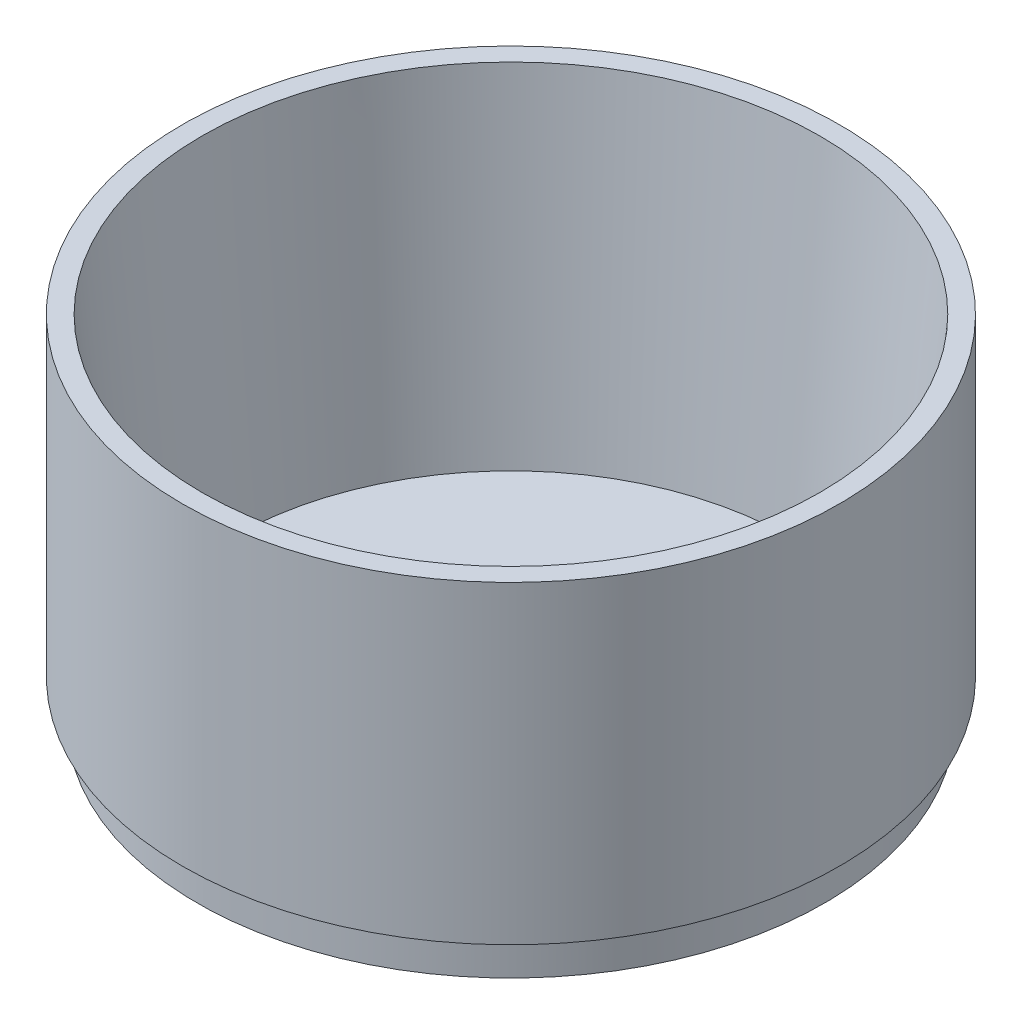
from build123d import *

# Parameters (mm, degrees)
SKETCH1_R           = 53.18125
BOSS_EXTRUDE1_DEPTH = 50.8
SKETCH2_R           = 50.8
SKETCH2_R_2         = 47.625
BOSS_EXTRUDE2_DEPTH = 6.35
SKETCH3_R           = 50.00625
CUT_EXTRUDE1_DEPTH  = 53.975
CUT_EXTRUDE1_DRAFT  = -5
SKETCH4_R           = 4.7625
CUT_EXTRUDE3_DEPTH  = 3.175


with BuildPart() as part:
    # Sketch1 → Boss-Extrude1 (new body)
    with BuildSketch(Plane(origin=(0, 0, 0), x_dir=(1, 0, 0), z_dir=(0, 1, 0))):
        with Locations(Location((0, 0, 0), (0, 0, 270))):
            Circle(SKETCH1_R)
    extrude(amount=BOSS_EXTRUDE1_DEPTH)

    # Sketch2 → Boss-Extrude2 (add)
    with BuildSketch(Plane.XZ):
        with Locations(Location((0, 0, 0), (0, 0, 270))):
            Circle(SKETCH2_R)
        Circle(SKETCH2_R_2, mode=Mode.SUBTRACT)
        Circle(SKETCH2_R_2)
    extrude(amount=BOSS_EXTRUDE2_DEPTH)


with BuildPart() as cut_extrude1_tool:
    # Sketch3 → Cut-Extrude1 (with draft: the straight prism first)
    with BuildSketch(Plane(origin=(0, 50.8, 0), x_dir=(1, 0, 0), z_dir=(0, 1, 0))):
        Circle(SKETCH3_R)
    extrude(amount=-CUT_EXTRUDE1_DEPTH)
    # Cut-Extrude1: the draft: its side faces are tilted about the plane it starts from
    cut_extrude1_sides = [cut_extrude1_tool.faces().sort_by_distance(p)[0] for p in [
        (-50.00625, 23.8125, 0),
    ]]
    draft(cut_extrude1_sides, Plane(origin=(0, 50.8, 0), x_dir=(1, 0, 0), z_dir=(0, 1, 0)), CUT_EXTRUDE1_DRAFT)


with BuildPart() as part_1:
    add(part.part)

    # Cut-Extrude1: cut by cut_extrude1_tool
    add(cut_extrude1_tool.part, mode=Mode.SUBTRACT)

    # Sketch4 → Cut-Extrude3 (cut)
    with BuildSketch(Plane(origin=(0, -3.175, 0), x_dir=(1, 0, 0), z_dir=(0, 1, 0))):
        with Locations(Location((7.487131795, -15.775986934, 0), (0, 0, 270))):
            Circle(SKETCH4_R)
        with Locations(Location((0, 0, 0), (0, 0, 270))):
            Circle(SKETCH4_R)
        with Locations(Location((-7.487131795, 15.775986934, 0), (0, 0, 270))):
            Circle(SKETCH4_R)
    extrude(amount=-CUT_EXTRUDE3_DEPTH, mode=Mode.SUBTRACT)


solid = part_1.part
